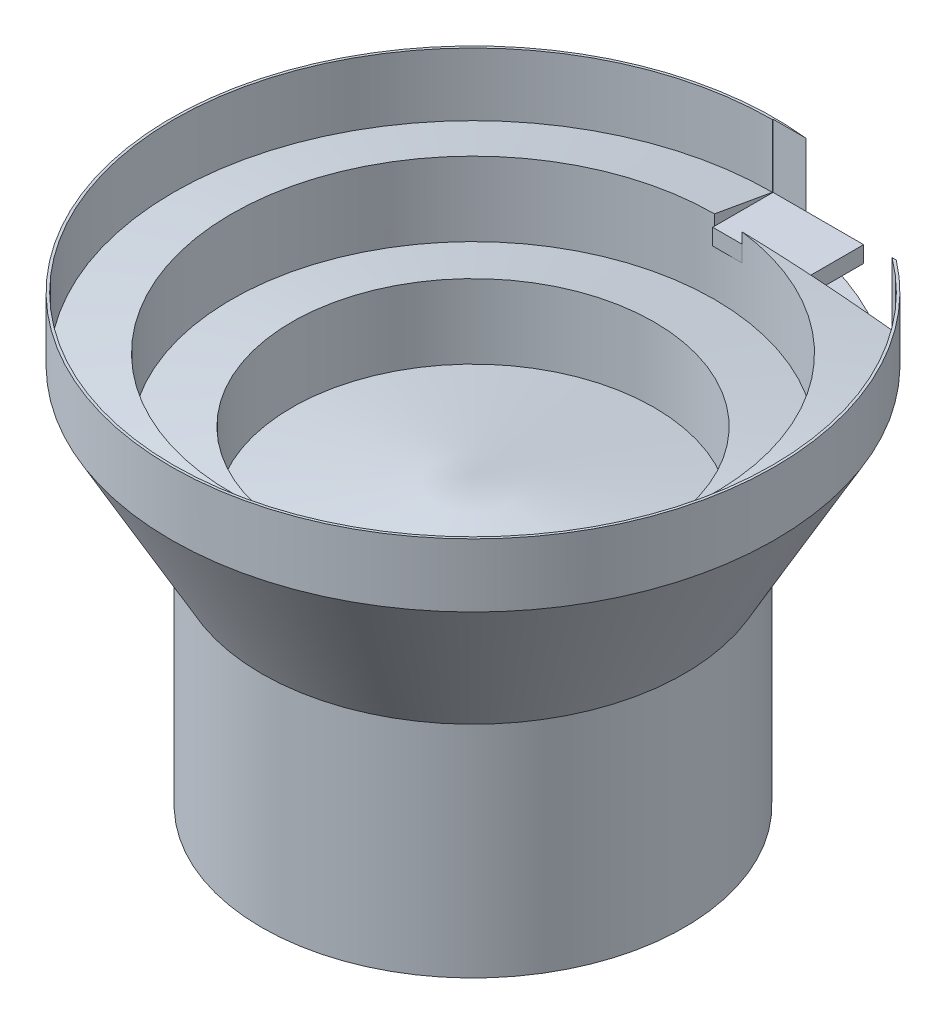
from build123d import *

# Parameters (mm, degrees)
SKETCH1_R           = 350
BOSS_EXTRUDE1_DEPTH = 364
SKETCH6_W           = 1000
SKETCH6_H           = 100
CUT_EXTRUDE1_DEPTH  = 133
SKETCH4_W           = 150
SKETCH4_H           = 100
BOSS_EXTRUDE2_DEPTH = 27


with BuildPart() as part:
    # Sketch1 → Boss-Extrude1 (new body)
    with BuildSketch(Plane(origin=(0, 0, 0), x_dir=(1, 0, 0), z_dir=(0, 1, 0))):
        Circle(SKETCH1_R)
    extrude(amount=BOSS_EXTRUDE1_DEPTH)

    # Sketch3 → Revolve1 (revolve)
    with BuildSketch(Plane(origin=(0, 0, 0), x_dir=(0, 0, -1), z_dir=(1, 0, 0))):
        Polygon((350, 364), (500, 631), (500, 736), (495.846454364, 736), (495.846454364, 631.732382161), (400, 648.632698071), (400, 526), (300, 543.632698071), (300, 421), (0, 473.898094213), (0, 364), align=None)
    revolve(axis=Axis((0, 364, 0), (0, 1, 0)))

    # Sketch6 → Cut-Extrude1 (cut, through all)
    with BuildSketch(Plane(origin=(0, 604, 0), x_dir=(-1, 0, 0), z_dir=(0, -1, 0))):
        with Locations((-500, 447)):
            Rectangle(SKETCH6_W, SKETCH6_H)
    extrude(amount=-CUT_EXTRUDE1_DEPTH, mode=Mode.SUBTRACT)


with BuildPart() as body_2:
    # Sketch4 → Boss-Extrude2 (new body)
    with BuildSketch(Plane(origin=(0, 604, 0), x_dir=(1, 0, 0), z_dir=(0, 1, 0))):
        with Locations((75, 447)):
            Rectangle(SKETCH4_W, SKETCH4_H)
    extrude(amount=BOSS_EXTRUDE2_DEPTH)


solid = Compound([part.part, body_2.part])
